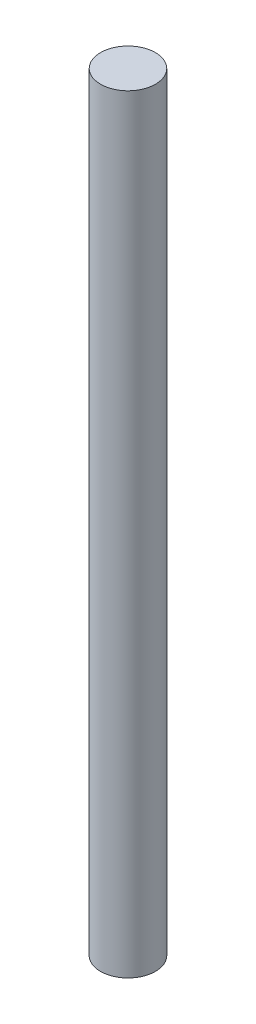
from build123d import *

# Parameters (mm, degrees)
ESQUISSE1_R        = 5
BOSS_EXTRU_1_DEPTH = 140


with BuildPart() as part:
    # Esquisse1 → Boss.-Extru.1 (new body)
    with BuildSketch(Plane(origin=(0, 0, 0), x_dir=(1, 0, 0), z_dir=(0, 1, 0))):
        Circle(ESQUISSE1_R)
    extrude(amount=BOSS_EXTRU_1_DEPTH)


solid = part.part
